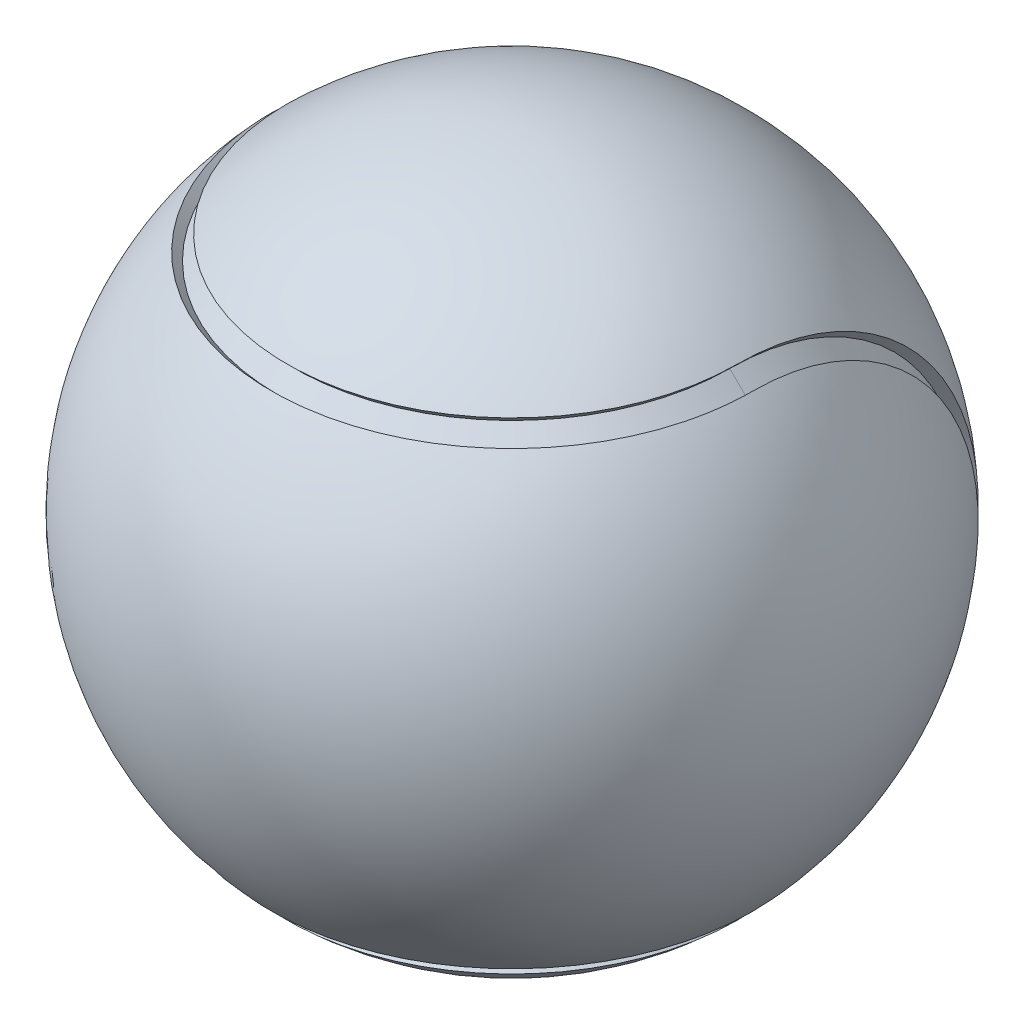
from build123d import *


with BuildPart() as part:
    # Sketch8 → Revolve2 (revolve)
    with BuildSketch(Plane.XY):
        with BuildLine():
            Line((-38.1, 0), (38.1, 0))
            ThreePointArc((38.1, 0), (0, 38.1), (-38.1, 0))
        make_face()
    revolve(axis=Axis((-38.1, 0, 0), (1, 0, 0)))

    # Cut-Sweep2: sweep along a curve in space
    with BuildLine() as cut_sweep2_path:
        ThreePointArc((26.940768363, -26.940768363, 0), (26.940768363, 0, -26.940768363), (26.940768363, 26.940768363, 0))
        ThreePointArc((26.940768363, 26.940768363, 0), (0, 26.940768363, 26.940768363), (-26.940768363, 26.940768363, 0))
        ThreePointArc((-26.940768363, 26.940768363, 0), (-26.940768363, 0, -26.940768363), (-26.940768363, -26.940768363, 0))
        ThreePointArc((-26.940768363, -26.940768363, 0), (0, -26.940768363, 26.940768363), (26.940768363, -26.940768363, 0))
    # Sketch13 → Cut-Sweep2 (sweep, cut)
    with BuildSketch(Plane.XY):
        Polygon((-26.940768363, 28.736819587), (-28.736819587, 26.940768363), (-26.940768363, 25.144717139), (-25.144717139, 26.940768363), align=None)
    sweep(path=cut_sweep2_path.line, mode=Mode.SUBTRACT)


solid = part.part
